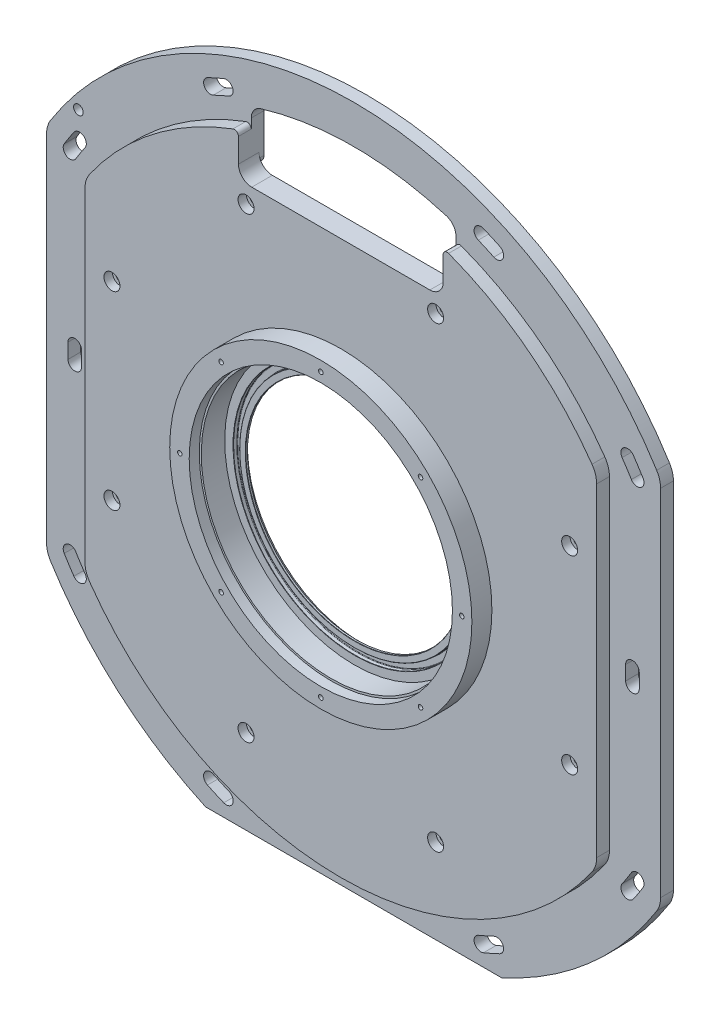
from build123d import *

# Parameters (mm, degrees)
SKETCH2_W                                      = 244.602
SKETCH2_H                                      = 244.602
CUT_EXTRUDE1_DEPTH                             = 2.5
F_4_40_TAPPED_HOLE1_D                          = 2.2606
F_4_40_TAPPED_HOLE1_DEPTH                      = 8.86
F_4_40_TAPPED_HOLE1_TIP                        = 0.679152758
FILLET2_R                                      = 0.254
FILLET3_R                                      = 0.127
CBORE_FOR_8_SOCKET_HEAD_CAP_SCREW1_D           = 4.4958
CBORE_FOR_8_SOCKET_HEAD_CAP_SCREW1_CBORE_D     = 7.9375
CBORE_FOR_8_SOCKET_HEAD_CAP_SCREW1_CBORE_DEPTH = 4.1656
CUT_EXTRUDE3_DEPTH                             = 6.35
CUT_EXTRUDE4_DEPTH                             = 13.7
FILLET4_R                                      = 12.7
F_4_40_TAPPED_HOLE2_D                          = 2.2606
F_4_40_TAPPED_HOLE2_DEPTH                      = 8.26
F_4_40_TAPPED_HOLE2_TIP                        = 0.679152758
CHAMFER1_SIZE                                  = 2.54
CUT_EXTRUDE5_DEPTH                             = 23.63
CUT_EXTRUDE8_DEPTH                             = 23.63
FILLET5_R                                      = 6.604
FILLET6_R                                      = 4
FILLET7_R                                      = 2
CHAMFER2_SIZE                                  = 25.4
FILLET8_R                                      = 3.302
F_3_16_0_1875_PRESS_DOWEL_HOLE1_D              = 4.7625
CUT_EXTRUDE9_DEPTH                             = 23.63
SKETCH21_R                                     = 57
CUT_EXTRUDE10_DEPTH                            = 0.5


with BuildPart() as part:
    # Sketch1 → Revolve1 (revolve)
    with BuildSketch(Plane(origin=(0, 0, 0), x_dir=(0, 0, -1), z_dir=(1, 0, 0)), mode=Mode.PRIVATE) as revolve1_sk:
        Polygon((0, 177.8), (0, 54), (-6, 54), (-6, 56.9849), (-4.0442, 56.9849), (-4.0442, 60.0837), (-6, 60.0837), (-6, 64.3349), (-17.63, 64.3349), (-17.63, 65.3349), (-22.63, 65.3349), (-22.63, 75), (-12.7, 75), (-12.7, 152.4), (-6.35, 152.4), (-6.35, 177.8), align=None)
    revolve(revolve1_sk.sketch.rotate(Axis((0, 0, 32.978361619), (0, 0, -1)), 180), axis=Axis((0, 0, 32.978361619), (0, 0, -1)))  # turned: the seam where the file's is

    # Sketch2 → Cut-Extrude1 (cut)
    with BuildSketch(Plane(origin=(0, 0, 0), x_dir=(-1, 0, 0), z_dir=(0, 0, -1))):
        Rectangle(SKETCH2_W, SKETCH2_H)
    extrude(amount=-CUT_EXTRUDE1_DEPTH, mode=Mode.SUBTRACT)

    # 4-40 Tapped Hole1
    with Locations(Plane.XY.offset(22.63)):
        with Locations((0, 70), (0, 0), (49.497474683, 49.497474683), (70, 0), (49.497474683, -49.497474683), (0, -70), (-49.497474683, -49.497474683), (-70, 0), (-49.497474683, 49.497474683), (0.037674457, 0.023286001), (0.194431033, 0.099140732)):
            Hole(F_4_40_TAPPED_HOLE1_D / 2, depth=F_4_40_TAPPED_HOLE1_DEPTH)
            with Locations((0, 0, -(F_4_40_TAPPED_HOLE1_DEPTH + F_4_40_TAPPED_HOLE1_TIP / 2))):  # 118° drill point
                Cone(0, F_4_40_TAPPED_HOLE1_D / 2, F_4_40_TAPPED_HOLE1_TIP, mode=Mode.SUBTRACT)

    # Fillet2
    fillet2_edges = [part.edges().sort_by_distance(p)[0] for p in [
        (0, 60.0837, 4.0442),
        (0, 56.9849, 4.0442),
    ]]
    fillet(fillet2_edges, radius=FILLET2_R)

    # Fillet3
    fillet3_edges = [part.edges().sort_by_distance(p)[0] for p in [
        (0, 60.0837, 6),
        (0, 56.9849, 6),
        (0, 54, 6),
    ]]
    fillet(fillet3_edges, radius=FILLET3_R)

    # CBORE for _8 Socket Head Cap Screw1 (through all)
    with Locations(Plane.XY.offset(12.7)):
        with Locations((-47.0552906, 113.601520749), (47.0552906, 113.601520749), (113.601520749, 47.0552906), (113.601520749, -47.0552906), (47.0552906, -113.601520749), (-47.0552906, -113.601520749), (-113.601520749, -47.0552906), (-113.601520749, 47.0552906), (0, 0)):
            CounterBoreHole(CBORE_FOR_8_SOCKET_HEAD_CAP_SCREW1_D / 2, CBORE_FOR_8_SOCKET_HEAD_CAP_SCREW1_CBORE_D / 2, CBORE_FOR_8_SOCKET_HEAD_CAP_SCREW1_CBORE_DEPTH)

    # Sketch11 → Cut-Extrude3 (cut)
    with BuildSketch(Plane.XY.offset(12.7)):
        with BuildLine():
            Line((-127, -84.242269675), (-127, 84.242269675))
            ThreePointArc((-127, 84.242269675), (-152.4, 0), (-127, -84.242269675))
        make_face()
        with BuildLine():
            Line((127, 84.242269675), (127, -84.242269675))
            ThreePointArc((127, -84.242269675), (152.4, 0), (127, 84.242269675))
        make_face()
    extrude(amount=-CUT_EXTRUDE3_DEPTH, mode=Mode.SUBTRACT)

    # Sketch11_3 → Cut-Extrude4 (cut, through all)
    with BuildSketch(Plane.XY.offset(12.7)):
        with BuildLine():
            Line((-152.4, -91.581002397), (-152.4, 91.581002397))
            ThreePointArc((-152.4, 91.581002397), (-177.8, 0), (-152.4, -91.581002397))
        make_face()
        with BuildLine():
            Line((152.4, 0), (152.4, -91.581002397))
            ThreePointArc((152.4, -91.581002397), (171.332367053, -47.519048812), (177.8, 0))
            ThreePointArc((177.8, 0), (171.332367053, 47.519048812), (152.4, 91.581002397))
            Line((152.4, 91.581002397), (152.4, 0))
        make_face()
    extrude(amount=-CUT_EXTRUDE4_DEPTH, mode=Mode.SUBTRACT)

    # Fillet4
    fillet4_edges = [part.edges().sort_by_distance(p)[0] for p in [
        (127, -84.242269675, 9.525),
        (127, 84.242269675, 9.525),
        (-127, 84.242269675, 9.525),
        (-127, -84.242269675, 9.525),
        (-152.4, 91.581002397, 3.175),
        (-152.4, -91.581002397, 3.175),
        (152.4, -91.581002397, 3.175),
        (152.4, 91.581002397, 3.175),
    ]]
    fillet(fillet4_edges, radius=FILLET4_R)

    # 4-40 Tapped Hole2
    with Locations(Plane(origin=(0, 0, 2.5), x_dir=(-1, 0, 0), z_dir=(0, 0, -1))):
        with Locations((-26.787840266, 64.671567276), (26.787840266, 64.671567276), (64.671567276, 26.787840266), (64.671567276, -26.787840266), (0, 0), (26.787840266, -64.671567276), (-26.787840266, -64.671567276), (-64.671567276, -26.787840266), (-64.671567276, 26.787840266)):
            Hole(F_4_40_TAPPED_HOLE2_D / 2, depth=F_4_40_TAPPED_HOLE2_DEPTH)
            with Locations((0, 0, -(F_4_40_TAPPED_HOLE2_DEPTH + F_4_40_TAPPED_HOLE2_TIP / 2))):  # 118° drill point
                Cone(0, F_4_40_TAPPED_HOLE2_D / 2, F_4_40_TAPPED_HOLE2_TIP, mode=Mode.SUBTRACT)

    # Chamfer1
    chamfer1_edges = [part.edges().sort_by_distance(p)[0] for p in [
        (0, 54, 2.5),
    ]]
    chamfer(chamfer1_edges, length=CHAMFER1_SIZE)

    # Sketch16 → Cut-Extrude5 (cut, through all)
    with BuildSketch(Plane(origin=(0, 0, 0), x_dir=(-1, 0, 0), z_dir=(0, 0, -1))):
        with BuildLine():
            ThreePointArc((-138.847296832, 95.427103266), (-141.29770768, 91.759804269), (-143.651280138, 88.029617686))
            ThreePointArc((-143.651280138, 88.029617686), (-142.535995786, 83.384124031), (-137.890502132, 84.499408383))
            ThreePointArc((-137.890502132, 84.499408383), (-135.631313855, 88.080005093), (-133.279170651, 91.600236167))
            ThreePointArc((-133.279170651, 91.600236167), (-134.149800192, 96.297732807), (-138.847296832, 95.427103266))
        make_face()
        with BuildLine():
            ThreePointArc((-64.473815855, 155.653560654), (-68.526257499, 153.912494322), (-72.53173467, 152.065944054))
            ThreePointArc((-72.53173467, 152.065944054), (-74.126495691, 147.562477859), (-69.623029496, 145.967716839))
            ThreePointArc((-69.623029496, 145.967716839), (-65.778182044, 147.740215792), (-61.888253512, 149.411460981))
            ThreePointArc((-61.888253512, 149.411460981), (-60.059984847, 153.825291989), (-64.473815855, 155.653560654))
        make_face()
        with BuildLine():
            ThreePointArc((-141.794104813, 3.713009308), (-141.842710768, 0), (-141.794104813, -3.713009308))
            ThreePointArc((-141.794104813, -3.713009308), (-138.328631471, -7.001620716), (-135.040020063, -3.536147374))
            ThreePointArc((-135.040020063, -3.536147374), (-135.086310768, 0), (-135.040020063, 3.536147374))
            ThreePointArc((-135.040020063, 3.536147374), (-138.328631471, 7.001620716), (-141.794104813, 3.713009308))
        make_face()
        with BuildLine():
            ThreePointArc((-143.651280138, -88.029617686), (-141.29770768, -91.759804269), (-138.847296832, -95.427103266))
            ThreePointArc((-138.847296832, -95.427103266), (-134.149800192, -96.297732807), (-133.279170651, -91.600236167))
            ThreePointArc((-133.279170651, -91.600236167), (-135.631313855, -88.080005093), (-137.890502132, -84.499408383))
            ThreePointArc((-137.890502132, -84.499408383), (-142.535995786, -83.384124031), (-143.651280138, -88.029617686))
        make_face()
        with BuildLine():
            ThreePointArc((-72.53173467, -152.065944054), (-68.526257499, -153.912494322), (-64.473815855, -155.653560654))
            ThreePointArc((-64.473815855, -155.653560654), (-60.059984847, -153.825291989), (-61.888253512, -149.411460981))
            ThreePointArc((-61.888253512, -149.411460981), (-65.778182044, -147.740215792), (-69.623029496, -145.967716839))
            ThreePointArc((-69.623029496, -145.967716839), (-74.126495691, -147.562477859), (-72.53173467, -152.065944054))
        make_face()
    cut_extrude5 = extrude(amount=-CUT_EXTRUDE5_DEPTH, mode=Mode.SUBTRACT)

    # Mirror1: Cut-Extrude5 across plane
    add(cut_extrude5.mirror(Plane(origin=(0, 0, 0), x_dir=(0, 0, 1), z_dir=(1, 0, 0))), mode=Mode.SUBTRACT)

    # Sketch17 → Cut-Extrude8 (cut, through all)
    with BuildSketch(Plane(origin=(0, 0, 0), x_dir=(-1, 0, 0), z_dir=(0, 0, -1))):
        with BuildLine():
            Line((50.8, 122.301), (50.8, 143.684097937))
            ThreePointArc((50.8, 143.684097937), (0, 152.4), (-50.8, 143.684097937))
            Line((-50.8, 143.684097937), (-50.8, 122.301))
            Line((-50.8, 122.301), (50.8, 122.301))
        make_face()
        with BuildLine():
            ThreePointArc((50.8, 150.402534886), (44.606641299, 152.35422558), (38.33864759, 154.051))
            Line((38.33864759, 154.051), (-38.33864759, 154.051))
            ThreePointArc((-38.33864759, 154.051), (-44.606641299, 152.35422558), (-50.8, 150.402534886))
            Line((-50.8, 150.402534886), (-50.8, 143.684097937))
            ThreePointArc((-50.8, 143.684097937), (0, 152.4), (50.8, 143.684097937))
            Line((50.8, 143.684097937), (50.8, 150.402534886))
        make_face()
        with BuildLine():
            Line((-38.33864759, 154.051), (38.33864759, 154.051))
            ThreePointArc((38.33864759, 154.051), (0, 158.75), (-38.33864759, 154.051))
        make_face()
    extrude(amount=-CUT_EXTRUDE8_DEPTH, mode=Mode.SUBTRACT)

    # Fillet5
    fillet5_edges = [part.edges().sort_by_distance(p)[0] for p in [
        (50.8, 150.402534886, 3.175),
        (-50.8, 122.301, 7.6),
        (-50.8, 150.402534886, 3.175),
        (50.8, 122.301, 7.6),
    ]]
    fillet(fillet5_edges, radius=FILLET5_R)

    # Fillet6
    fillet6_edges = [part.edges().sort_by_distance(p)[0] for p in [
        (50.8, 122.301, 1.25),
        (-50.8, 122.301, 1.25),
    ]]
    fillet(fillet6_edges, radius=FILLET6_R)

    # Fillet7
    fillet7_edges = [part.edges().sort_by_distance(p)[0] for p in [
        (50.8, 143.684097937, 9.525),
        (-50.8, 143.684097937, 9.525),
    ]]
    fillet(fillet7_edges, radius=FILLET7_R)

    # Chamfer2
    chamfer2_edges = [part.edges().sort_by_distance(p)[0] for p in [
        (122.301, -122.301, 1.25),
        (122.301, 122.301, 1.25),
        (-122.301, 122.301, 1.25),
        (-122.301, -122.301, 1.25),
    ]]
    chamfer(chamfer2_edges, length=CHAMFER2_SIZE)

    # Fillet8
    fillet8_edges = [part.edges().sort_by_distance(p)[0] for p in [
        (-96.901, -122.301, 1.25),
        (96.901, -122.301, 1.25),
        (122.301, 96.901, 1.25),
        (122.301, -96.901, 1.25),
        (-122.301, 96.901, 1.25),
        (-122.301, -96.901, 1.25),
        (-96.901, 122.301, 1.25),
        (96.901, 122.301, 1.25),
    ]]
    fillet(fillet8_edges, radius=FILLET8_R)

    # 3_16 _0.1875_ Press Dowel Hole1 (through all)
    with Locations(Plane(origin=(0, 0, 0), x_dir=(-1, 0, 0), z_dir=(0, 0, -1))):
        with Locations((136.613188579, 106.201756636)):
            Hole(F_3_16_0_1875_PRESS_DOWEL_HOLE1_D / 2)

    # Sketch20 → Cut-Extrude9 (cut, through all)
    with BuildSketch(Plane(origin=(0, 0, 0), x_dir=(-1, 0, 0), z_dir=(0, 0, -1))):
        with BuildLine():
            Line((73.437962764, -161.925), (-73.437962764, -161.925))
            ThreePointArc((-73.437962764, -161.925), (0, -177.8), (73.437962764, -161.925))
        make_face()
    extrude(amount=-CUT_EXTRUDE9_DEPTH, mode=Mode.SUBTRACT)

    # Sketch21 → Cut-Extrude10 (cut)
    with BuildSketch(Plane(origin=(0, 0, 2.5), x_dir=(-1, 0, 0), z_dir=(0, 0, -1))):
        with Locations(Location((0, 0, 0), (0, 0, 90))):  # turned: the seam where the file's is
            Circle(SKETCH21_R)
    extrude(amount=-CUT_EXTRUDE10_DEPTH, mode=Mode.SUBTRACT)


solid = part.part
